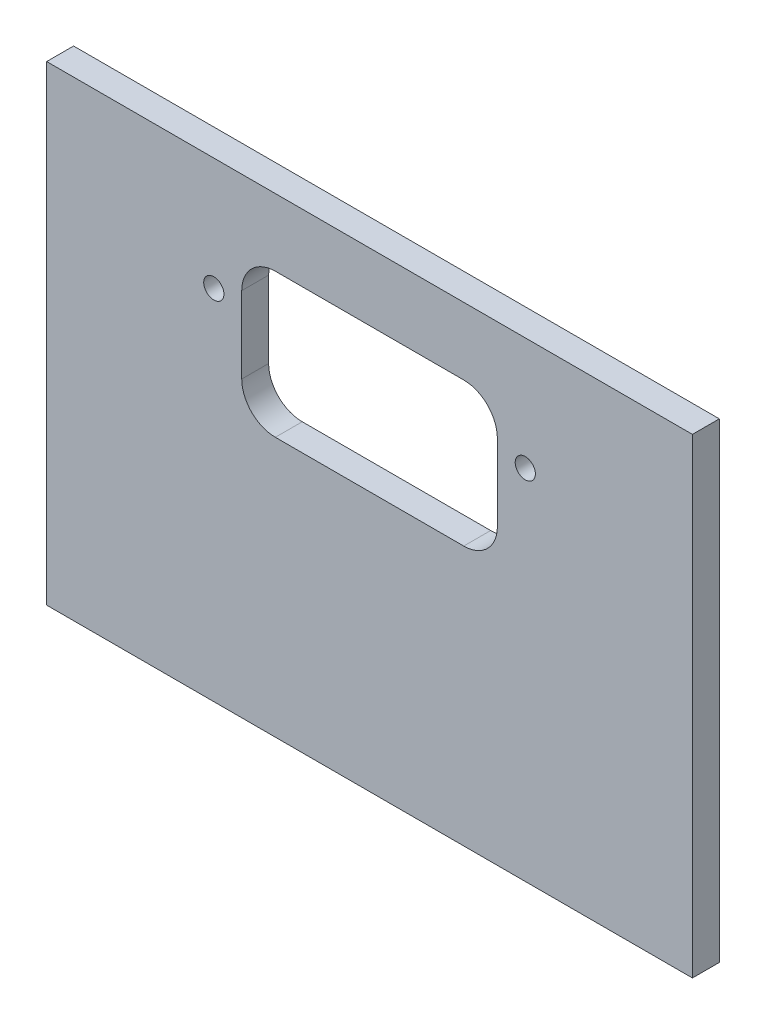
from build123d import *

# Parameters (mm, degrees)
ESBO_O1_W                = 96.01
ESBO_O1_H                = 70
RESSALTO_EXTRUS_O1_DEPTH = 4
ESBO_O2_R                = 1.25
CORTE_EXTRUS_O1_DEPTH    = 12
ESBO_O3_R                = 1.5
ESBO_O3_W                = 38.01
ESBO_O3_H                = 21.381971147
CORTE_EXTRUS_O2_DEPTH    = 10
FILETE1_R                = 5


with BuildPart() as part:
    # Esboço1 → Ressalto-extrusão1 (new body)
    with BuildSketch(Plane.XY):
        with Locations((48.005, -35)):
            Rectangle(ESBO_O1_W, ESBO_O1_H)
    extrude(amount=RESSALTO_EXTRUS_O1_DEPTH)

    # Esboço2 → Corte-extrusão1 (cut)
    with BuildSketch(Plane(origin=(0, -70, 0), x_dir=(-1, 0, 0), z_dir=(0, -1, 0))):
        with Locations((-48.005, -2)):
            Circle(ESBO_O2_R)
        with Locations((-10, -2)):
            Circle(ESBO_O2_R)
        with Locations((-30, -2)):
            Circle(ESBO_O2_R)
        with Locations((-66.01, -2)):
            Circle(ESBO_O2_R)
        with Locations((-86.01, -2)):
            Circle(ESBO_O2_R)
    extrude(amount=-CORTE_EXTRUS_O1_DEPTH, mode=Mode.SUBTRACT)

    # Esboço3 → Corte-extrusão2 (cut)
    with BuildSketch(Plane.XY.offset(4)):
        with Locations((24.85, -16.78)):
            Circle(ESBO_O3_R)
        with Locations((71.16, -16.78)):
            Circle(ESBO_O3_R)
        with Locations((48.005, -20.690985574)):
            Rectangle(ESBO_O3_W, ESBO_O3_H)
    extrude(amount=-CORTE_EXTRUS_O2_DEPTH, mode=Mode.SUBTRACT)

    # Filete1
    filete1_edges = [part.edges().sort_by_distance(p)[0] for p in [
        (29, -31.381971147, 2),
        (29, -10, 2),
        (67.01, -10, 2),
        (67.01, -31.381971147, 2),
    ]]
    fillet(filete1_edges, radius=FILETE1_R)


solid = part.part
